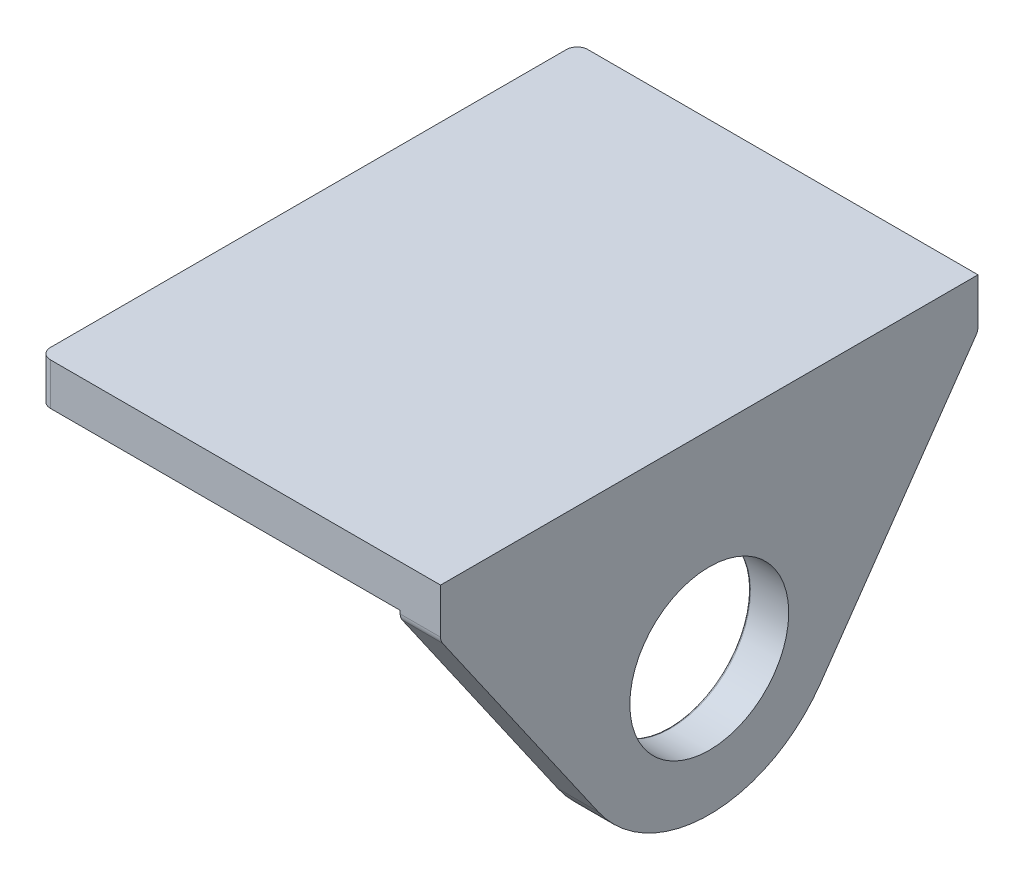
from build123d import *

# Parameters (mm, degrees)
SKETCH1_W           = 47.4218
SKETCH1_H           = 63.5762
BOSS_EXTRUDE1_DEPTH = 4.9784
SKETCH3_W           = 4.7752
SKETCH3_H           = 63.5762
BOSS_EXTRUDE2_DEPTH = 34.4424
SKETCH4_R           = 9.398
CUT_EXTRUDE1_DEPTH  = 5.7752
FILLET1_R           = 1.27
FILLET2_R           = 1.27
FILLET3_R           = 0.254


with BuildPart() as part:
    # Sketch1 → Boss-Extrude1 (new body)
    with BuildSketch(Plane(origin=(0, 0, 0), x_dir=(1, 0, 0), z_dir=(0, 1, 0))):
        with Locations((23.7109, 31.7881)):
            Rectangle(SKETCH1_W, SKETCH1_H)
    extrude(amount=BOSS_EXTRUDE1_DEPTH)

    # Sketch3 → Boss-Extrude2 (add)
    with BuildSketch(Plane.XZ):
        with Locations((45.0342, -31.7881)):
            Rectangle(SKETCH3_W, SKETCH3_H)
    extrude(amount=BOSS_EXTRUDE2_DEPTH)

    # Sketch4 → Cut-Extrude1 (cut, through all)
    with BuildSketch(Plane.ZY.offset(-42.6466)):
        with BuildLine():
            Line((0, -34.4424), (0, -0.762))
            Line((0, -0.762), (-18.65127846, -27.577572639))
            ThreePointArc((-18.65127846, -27.577572639), (-24.376927103, -32.622731271), (-31.7881, -34.4424))
            Line((-31.7881, -34.4424), (0, -34.4424))
        make_face()
        with BuildLine():
            Line((-44.92492154, -27.577572639), (-63.5762, -0.762))
            Line((-63.5762, -0.762), (-63.5762, -34.4424))
            Line((-63.5762, -34.4424), (-31.7881, -34.4424))
            ThreePointArc((-31.7881, -34.4424), (-39.199272897, -32.622731271), (-44.92492154, -27.577572639))
        make_face()
        with Locations((-31.7881, -18.4404)):
            Circle(SKETCH4_R)
    extrude(amount=-CUT_EXTRUDE1_DEPTH, mode=Mode.SUBTRACT)

    # Fillet1
    fillet1_edges = [part.edges().sort_by_distance(p)[0] for p in [
        (45.0342, -0.762, 0),
        (45.0342, -0.762, -63.5762),
    ]]
    fillet(fillet1_edges, radius=FILLET1_R)

    # Fillet2
    fillet2_edges = [part.edges().sort_by_distance(p)[0] for p in [
        (0, 2.4892, -63.5762),
        (0, 2.4892, 0),
    ]]
    fillet(fillet2_edges, radius=FILLET2_R)

    # Fillet3
    fillet3_edges = [part.edges().sort_by_distance(p)[0] for p in [
        (42.6466, -18.4404, -41.1861),
    ]]
    fillet(fillet3_edges, radius=FILLET3_R)


solid = part.part
